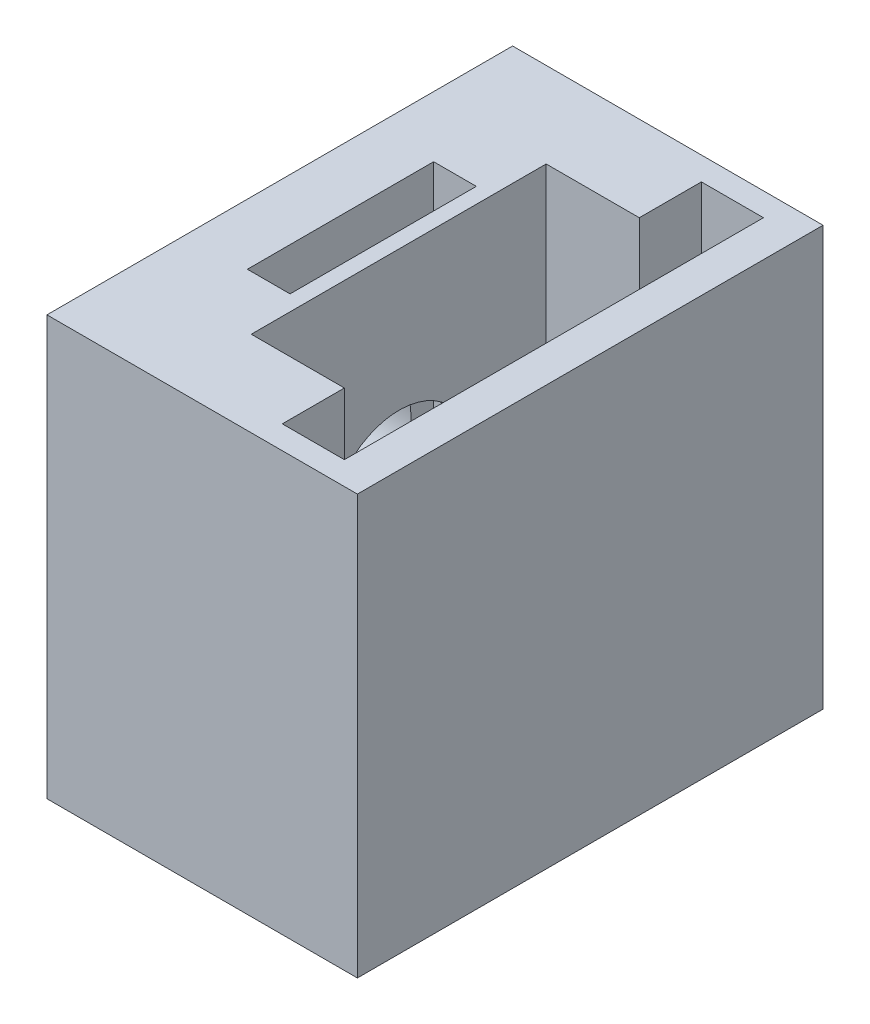
from build123d import *

# Parameters (mm, degrees)
SKETCH2_W           = 30
SKETCH2_H           = 27
BOSS_EXTRUDE1_DEPTH = 20
SKETCH6_W           = 4
SKETCH6_H           = 27
CUT_EXTRUDE4_DEPTH  = 26
SKETCH9_W           = 6
SKETCH9_H           = 19
CUT_EXTRUDE5_DEPTH  = 20
SKETCH11_R          = 5
CUT_EXTRUDE8_DEPTH  = 0.5
SKETCH12_W          = 2.75
SKETCH12_H          = 12
CUT_EXTRUDE12_DEPTH = 17.5
SKETCH15_R          = 4.5
CUT_EXTRUDE13_DEPTH = 10


with BuildPart() as part:
    # Sketch2 → Boss-Extrude1 (new body)
    with BuildSketch(Plane(origin=(0, 0, 0), x_dir=(0, 0, -1), z_dir=(1, 0, 0))):
        with Locations((15, 13.5)):
            Rectangle(SKETCH2_W, SKETCH2_H)
    extrude(amount=BOSS_EXTRUDE1_DEPTH)

    # Sketch6 → Cut-Extrude4 (cut)
    with BuildSketch(Plane(origin=(2.296116437, 27, -0.293484995), x_dir=(1, 0, 0), z_dir=(0, 1, 0))):
        with Locations((13.365844825, 14.706515005)):
            Rectangle(SKETCH6_W, SKETCH6_H)
    extrude(amount=-CUT_EXTRUDE4_DEPTH, mode=Mode.SUBTRACT)

    # Sketch9 → Cut-Extrude5 (cut)
    with BuildSketch(Plane(origin=(0, 27, 0), x_dir=(1, 0, 0), z_dir=(0, 1, 0))):
        with Locations((10.661961261, 15)):
            Rectangle(SKETCH9_W, SKETCH9_H)
    extrude(amount=-CUT_EXTRUDE5_DEPTH, mode=Mode.SUBTRACT)

    # Sketch11 → Cut-Extrude8 (cut)
    with BuildSketch(Plane.ZY):
        with Locations((-15.1, 13.5)):
            Circle(SKETCH11_R)
    extrude(amount=-CUT_EXTRUDE8_DEPTH, mode=Mode.SUBTRACT)

    # Sketch12 → Cut-Extrude12 (cut)
    with BuildSketch(Plane(origin=(0, 27, 0), x_dir=(1, 0, 0), z_dir=(0, 1, 0))):
        with Locations((5.286961261, 15)):
            Rectangle(SKETCH12_W, SKETCH12_H)
    extrude(amount=-CUT_EXTRUDE12_DEPTH, mode=Mode.SUBTRACT)

    # Sketch15 → Cut-Extrude13 (cut)
    with BuildSketch(Plane.ZY.offset(-0.5)):
        with Locations((-15.04, 13.5)):
            Circle(SKETCH15_R)
    extrude(amount=-CUT_EXTRUDE13_DEPTH, mode=Mode.SUBTRACT)


solid = part.part
